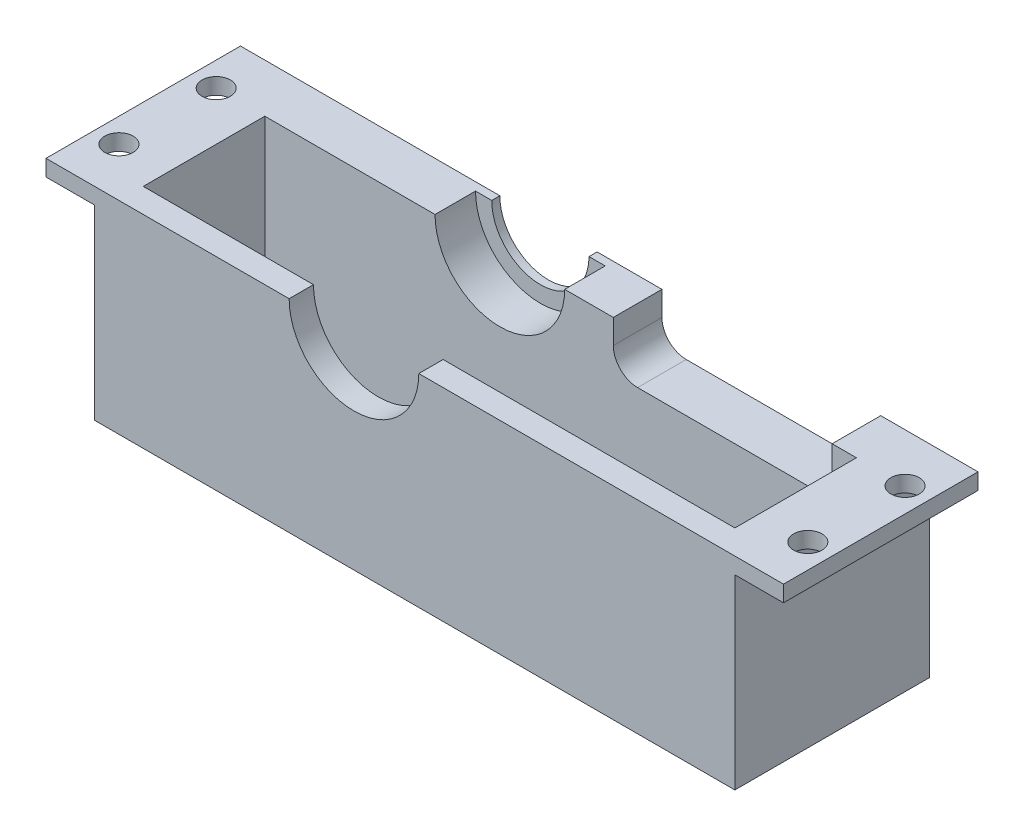
from build123d import *

# Parameters (mm, degrees)
SALIENTE_EXTRUIR1_DEPTH    = 3
CROQUIS4_W                 = 3
CROQUIS4_H                 = 25
SALIENTE_EXTRUIR4_DEPTH    = 15
SALIENTE_EXTRUIR6_DEPTH    = 5
CROQUIS11_W                = 23
CROQUIS11_H                = 2
SALIENTE_EXTRUIR11_DEPTH   = 6
CROQUIS12_W                = 23
CROQUIS12_H                = 2
SALIENTE_EXTRUIR12_DEPTH   = 6
SALIENTE_EXTRUIR23_DEPTH   = 1
CROQUIS27_W                = 24
CROQUIS27_H                = 2
SALIENTE_EXTRUIR26_DEPTH   = 6
CROQUIS28_W                = 24
CROQUIS28_H                = 2
SALIENTE_EXTRUIR27_DEPTH   = 6
CROQUIS13_R                = 1.75
CORTAR_EXTRUIR1_DEPTH      = 1
CORTAR_EXTRUIR1_DEPTH_BACK = 26
REDONDEO1_R                = 3


with BuildPart() as part:
    # Croquis1 → Saliente-Extruir1 (new body)
    with BuildSketch(Plane.XY):
        with BuildLine():
            Line((79, 0), (79, 25))
            Line((79, 25), (40, 25))
            ThreePointArc((40, 25), (32, 17), (24, 25))
            Line((24, 25), (0, 25))
            Line((0, 25), (0, 0))
            Line((0, 0), (79, 0))
        make_face()
    extrude(amount=SALIENTE_EXTRUIR1_DEPTH)

    # Croquis4 → Saliente-Extruir4 (add)
    with BuildSketch(Plane(origin=(0, 0, 0), x_dir=(-1, 0, 0), z_dir=(0, 0, -1))):
        with Locations((-77.5, 12.5)):
            Rectangle(CROQUIS4_W, CROQUIS4_H)
        with Locations((-1.5, 12.5)):
            Rectangle(CROQUIS4_W, CROQUIS4_H)
    extrude(amount=SALIENTE_EXTRUIR4_DEPTH)

    # Croquis6 → Saliente-Extruir6 (add)
    with BuildSketch(Plane(origin=(0, 0, -15), x_dir=(-1, 0, 0), z_dir=(0, 0, -1))):
        with BuildLine():
            Line((-79, 25), (-79, 0))
            Line((-79, 0), (0, 0))
            Line((0, 0), (0, 25))
            Line((0, 25), (-24, 25))
            ThreePointArc((-24, 25), (-32, 17), (-40, 25))
            Line((-40, 25), (-46, 25))
            Line((-46, 25), (-46, 19))
            Line((-46, 19), (-73, 19))
            Line((-73, 19), (-73, 25))
            Line((-73, 25), (-79, 25))
        make_face()
    extrude(amount=SALIENTE_EXTRUIR6_DEPTH)

    # Croquis11 → Saliente-Extruir11 (add)
    with BuildSketch(Plane(origin=(76, 0, 0), x_dir=(0, 0, -1), z_dir=(1, 0, 0))):
        with Locations((8.5, 1)):
            Rectangle(CROQUIS11_W, CROQUIS11_H)
    extrude(amount=-SALIENTE_EXTRUIR11_DEPTH)

    # Croquis12 → Saliente-Extruir12 (add)
    with BuildSketch(Plane.ZY.offset(-3)):
        with Locations((-8.5, 1)):
            Rectangle(CROQUIS12_W, CROQUIS12_H)
    extrude(amount=-SALIENTE_EXTRUIR12_DEPTH)

    # Croquis24 → Saliente-Extruir23 (add)
    with BuildSketch(Plane(origin=(0, 0, -20), x_dir=(-1, 0, 0), z_dir=(0, 0, -1))):
        with BuildLine():
            Line((-79, 0), (-79, 25))
            Line((-79, 25), (-73, 25))
            Line((-73, 25), (-73, 19))
            Line((-73, 19), (-46, 19))
            Line((-46, 19), (-46, 25))
            Line((-46, 25), (-40, 25))
            Line((-40, 25), (-38, 25))
            ThreePointArc((-38, 25), (-32, 19), (-26, 25))
            Line((-26, 25), (0, 25))
            Line((0, 25), (0, 0))
            Line((0, 0), (-79, 0))
        make_face()
    extrude(amount=SALIENTE_EXTRUIR23_DEPTH)

    # Croquis27 → Saliente-Extruir26 (add)
    with BuildSketch(Plane(origin=(79, 0, 0), x_dir=(0, 0, -1), z_dir=(1, 0, 0))):
        with Locations((9, 24)):
            Rectangle(CROQUIS27_W, CROQUIS27_H)
    extrude(amount=SALIENTE_EXTRUIR26_DEPTH)

    # Croquis28 → Saliente-Extruir27 (add)
    with BuildSketch(Plane.ZY):
        with Locations((-9, 24)):
            Rectangle(CROQUIS28_W, CROQUIS28_H)
    extrude(amount=SALIENTE_EXTRUIR27_DEPTH)

    # Croquis13 → Cortar-Extruir1 (cut, two sides)
    with BuildSketch(Plane(origin=(0, 25, 0), x_dir=(1, 0, 0), z_dir=(0, 1, 0))) as cortar_extruir1_sk:
        with Locations((82, 15)):
            Circle(CROQUIS13_R)
        with Locations((82, 3)):
            Circle(CROQUIS13_R)
        with Locations((73, 11)):
            Circle(CROQUIS13_R)
        with Locations((73, 4)):
            Circle(CROQUIS13_R)
        with Locations((6, 4)):
            Circle(CROQUIS13_R)
        with Locations((6, 11)):
            Circle(CROQUIS13_R)
        with Locations((-3, 3)):
            Circle(CROQUIS13_R)
        with Locations((-3, 15)):
            Circle(CROQUIS13_R)
    extrude(amount=CORTAR_EXTRUIR1_DEPTH, mode=Mode.SUBTRACT)
    extrude(cortar_extruir1_sk.sketch, amount=-CORTAR_EXTRUIR1_DEPTH_BACK, mode=Mode.SUBTRACT)

    # Redondeo1
    redondeo1_edges = [part.edges().sort_by_distance(p)[0] for p in [
        (46, 19, -18),
        (73, 19, -18),
    ]]
    fillet(redondeo1_edges, radius=REDONDEO1_R)


solid = part.part
